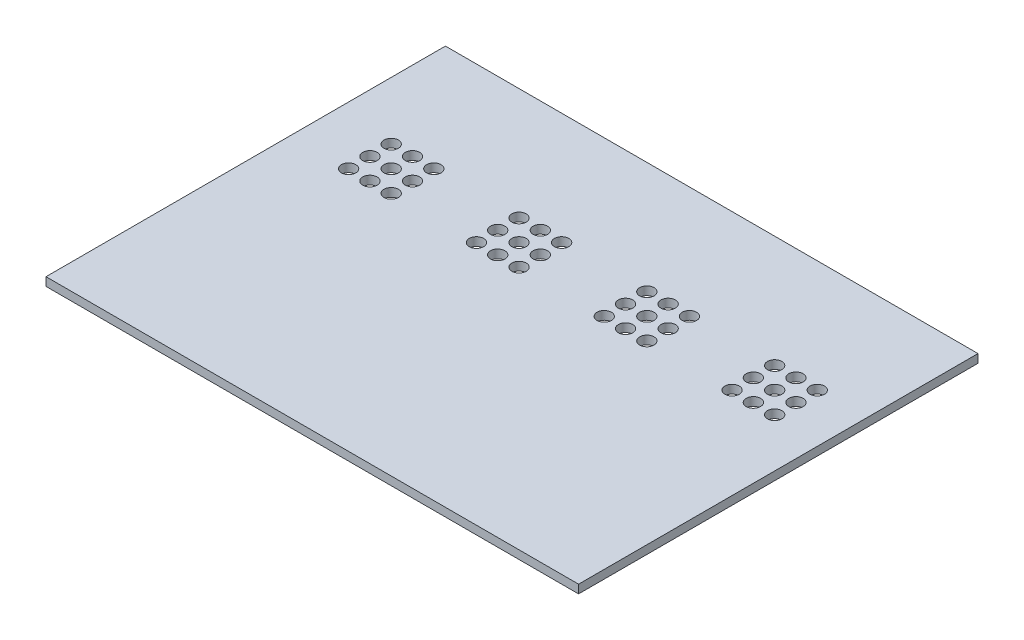
from build123d import *

# Parameters (mm, degrees)
SKETCH1_W           = 100
SKETCH1_H           = 75
BOSS_EXTRUDE1_DEPTH = 1.5875
SKETCH4_R           = 1.35
CUT_EXTRUDE1_DEPTH  = 2.5875


with BuildPart() as part:
    # Sketch1 → Boss-Extrude1 (new body)
    with BuildSketch(Plane(origin=(0, 0, 0), x_dir=(1, 0, 0), z_dir=(0, 1, 0))):
        with Locations((50, 37.5)):
            Rectangle(SKETCH1_W, SKETCH1_H)
    extrude(amount=BOSS_EXTRUDE1_DEPTH)

    # Sketch4 → Cut-Extrude1 (cut, through all)
    with BuildSketch(Plane(origin=(0, 1.5875, 0), x_dir=(1, 0, 0), z_dir=(0, 1, 0))):
        with Locations((10.86, 53.96)):
            Circle(SKETCH4_R)
        with Locations((10.86, 49.96)):
            Circle(SKETCH4_R)
        with Locations((10.86, 45.96)):
            Circle(SKETCH4_R)
        with Locations((14.86, 53.96)):
            Circle(SKETCH4_R)
        with Locations((14.86, 49.96)):
            Circle(SKETCH4_R)
        with Locations((14.86, 45.96)):
            Circle(SKETCH4_R)
        with Locations((18.86, 53.96)):
            Circle(SKETCH4_R)
        with Locations((18.86, 49.96)):
            Circle(SKETCH4_R)
        with Locations((18.86, 45.96)):
            Circle(SKETCH4_R)
        with Locations((34.86, 53.96)):
            Circle(SKETCH4_R)
        with Locations((34.86, 49.96)):
            Circle(SKETCH4_R)
        with Locations((34.86, 45.96)):
            Circle(SKETCH4_R)
        with Locations((38.86, 53.96)):
            Circle(SKETCH4_R)
        with Locations((38.86, 49.96)):
            Circle(SKETCH4_R)
        with Locations((38.86, 45.96)):
            Circle(SKETCH4_R)
        with Locations((42.86, 53.96)):
            Circle(SKETCH4_R)
        with Locations((42.86, 49.96)):
            Circle(SKETCH4_R)
        with Locations((42.86, 45.96)):
            Circle(SKETCH4_R)
        with Locations((58.86, 53.96)):
            Circle(SKETCH4_R)
        with Locations((58.86, 49.96)):
            Circle(SKETCH4_R)
        with Locations((58.86, 45.96)):
            Circle(SKETCH4_R)
        with Locations((62.86, 53.96)):
            Circle(SKETCH4_R)
        with Locations((62.86, 49.96)):
            Circle(SKETCH4_R)
        with Locations((62.86, 45.96)):
            Circle(SKETCH4_R)
        with Locations((66.86, 53.96)):
            Circle(SKETCH4_R)
        with Locations((66.86, 49.96)):
            Circle(SKETCH4_R)
        with Locations((66.86, 45.96)):
            Circle(SKETCH4_R)
        with Locations((82.86, 53.96)):
            Circle(SKETCH4_R)
        with Locations((82.86, 49.96)):
            Circle(SKETCH4_R)
        with Locations((82.86, 45.96)):
            Circle(SKETCH4_R)
        with Locations((86.86, 53.96)):
            Circle(SKETCH4_R)
        with Locations((86.86, 49.96)):
            Circle(SKETCH4_R)
        with Locations((86.86, 45.96)):
            Circle(SKETCH4_R)
        with Locations((90.86, 53.96)):
            Circle(SKETCH4_R)
        with Locations((90.86, 49.96)):
            Circle(SKETCH4_R)
        with Locations((90.86, 45.96)):
            Circle(SKETCH4_R)
    extrude(amount=-CUT_EXTRUDE1_DEPTH, mode=Mode.SUBTRACT)


solid = part.part
